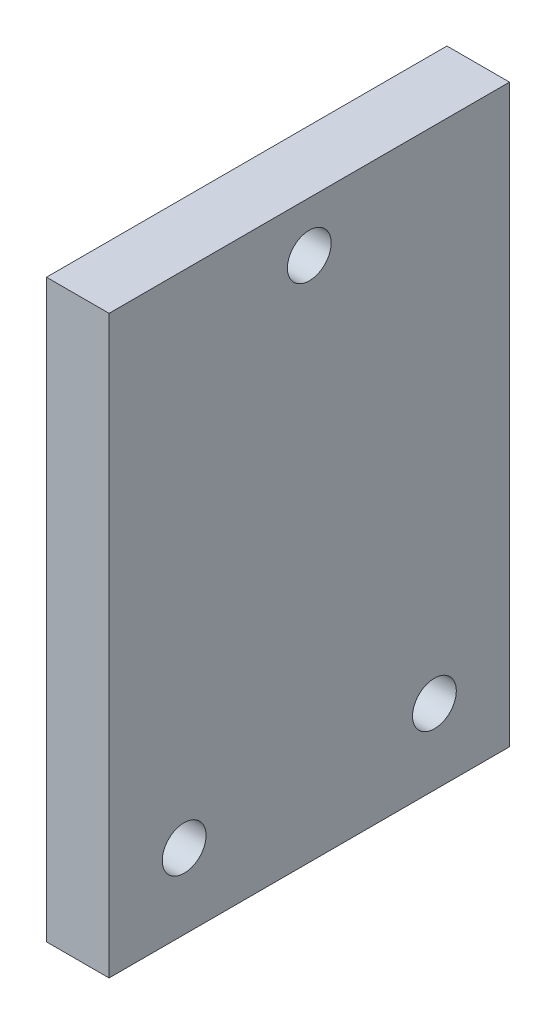
from build123d import *

# Parameters (mm, degrees)
SKETCH1_W           = 55
SKETCH1_H           = 32
BOSS_EXTRUDE1_DEPTH = 46
SKETCH2_W           = 45
SKETCH2_H           = 32
CUT_EXTRUDE1_DEPTH  = 45
SKETCH3_R           = 1.75
CUT_EXTRUDE2_DEPTH  = 47
SKETCH4_R           = 1.75
CUT_EXTRUDE3_DEPTH  = 56
SKETCH7_W           = 32
SKETCH7_H           = 46
CUT_EXTRUDE5_DEPTH  = 50


with BuildPart() as part:
    # Sketch1 → Boss-Extrude1 (new body)
    with BuildSketch(Plane(origin=(0, 0, 0), x_dir=(1, 0, 0), z_dir=(0, 1, 0))):
        with Locations((27.5, 16)):
            Rectangle(SKETCH1_W, SKETCH1_H)
    extrude(amount=BOSS_EXTRUDE1_DEPTH)

    # Sketch2 → Cut-Extrude1 (cut)
    with BuildSketch(Plane.XZ):
        with Locations((27.5, -16)):
            Rectangle(SKETCH2_W, SKETCH2_H)
    extrude(amount=-CUT_EXTRUDE1_DEPTH, mode=Mode.SUBTRACT)

    # Sketch3 → Cut-Extrude2 (cut, through all)
    with BuildSketch(Plane(origin=(0, 46, 0), x_dir=(1, 0, 0), z_dir=(0, 1, 0))):
        with Locations((43.5, 26)):
            Circle(SKETCH3_R)
        with Locations((43.5, 6)):
            Circle(SKETCH3_R)
        with Locations((11.5, 26)):
            Circle(SKETCH3_R)
        with Locations((11.5, 6)):
            Circle(SKETCH3_R)
    extrude(amount=-CUT_EXTRUDE2_DEPTH, mode=Mode.SUBTRACT)

    # Sketch4 → Cut-Extrude3 (cut, through all)
    with BuildSketch(Plane(origin=(55, 0, 0), x_dir=(0, 0, -1), z_dir=(1, 0, 0))):
        with Locations((6, 6)):
            Circle(SKETCH4_R)
        with Locations((26, 6)):
            Circle(SKETCH4_R)
        with Locations((16, 42)):
            Circle(SKETCH4_R)
    extrude(amount=-CUT_EXTRUDE3_DEPTH, mode=Mode.SUBTRACT)

    # Sketch7 → Cut-Extrude5 (cut)
    with BuildSketch(Plane.ZY):
        with Locations((-16, 23)):
            Rectangle(SKETCH7_W, SKETCH7_H)
    extrude(amount=-CUT_EXTRUDE5_DEPTH, mode=Mode.SUBTRACT)


solid = part.part
